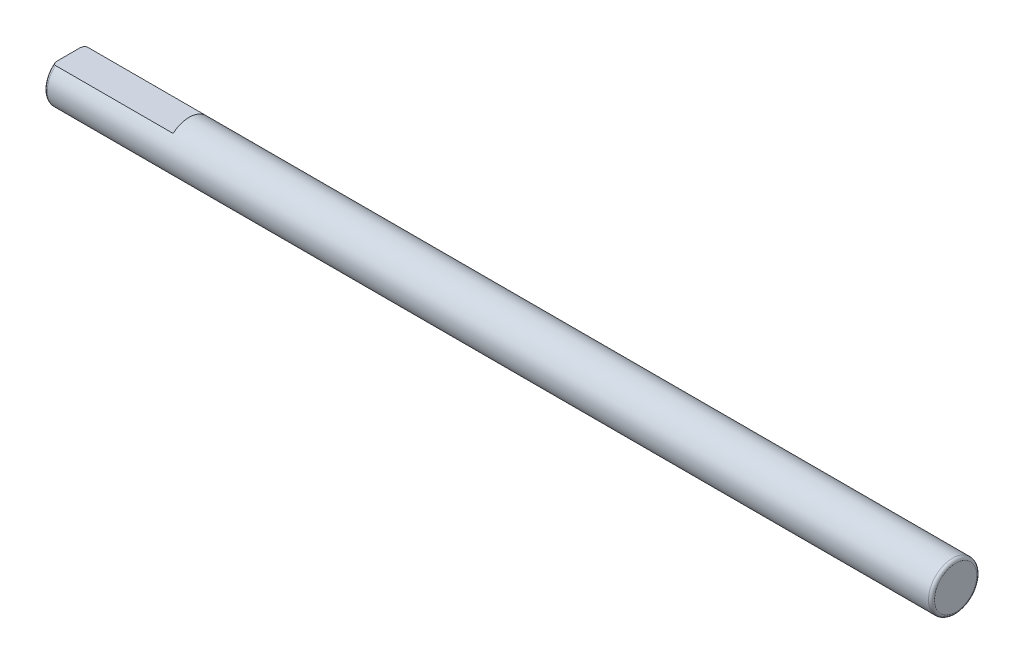
from build123d import *

# Parameters (mm, degrees)
SKETCH1_R           = 4
BOSS_EXTRUDE1_DEPTH = 147
FILLET1_R           = 0.5
SKETCH2_W           = 6.178297582
SKETCH2_H           = 2
CUT_EXTRUDE1_DEPTH  = 20


with BuildPart() as part:
    # Sketch1 → Boss-Extrude1 (new body)
    with BuildSketch(Plane(origin=(0, 0, 0), x_dir=(0, 0, -1), z_dir=(1, 0, 0))):
        Circle(SKETCH1_R)
    extrude(amount=BOSS_EXTRUDE1_DEPTH)

    # Fillet1
    fillet1_edges = [part.edges().sort_by_distance(p)[0] for p in [
        (0, 0, 4),
        (147, 0, 4),
    ]]
    fillet(fillet1_edges, radius=FILLET1_R)

    # Sketch2 → Cut-Extrude1 (cut)
    with BuildSketch(Plane.ZY):
        with Locations((0, 4)):
            Rectangle(SKETCH2_W, SKETCH2_H)
    extrude(amount=-CUT_EXTRUDE1_DEPTH, mode=Mode.SUBTRACT)


solid = part.part
